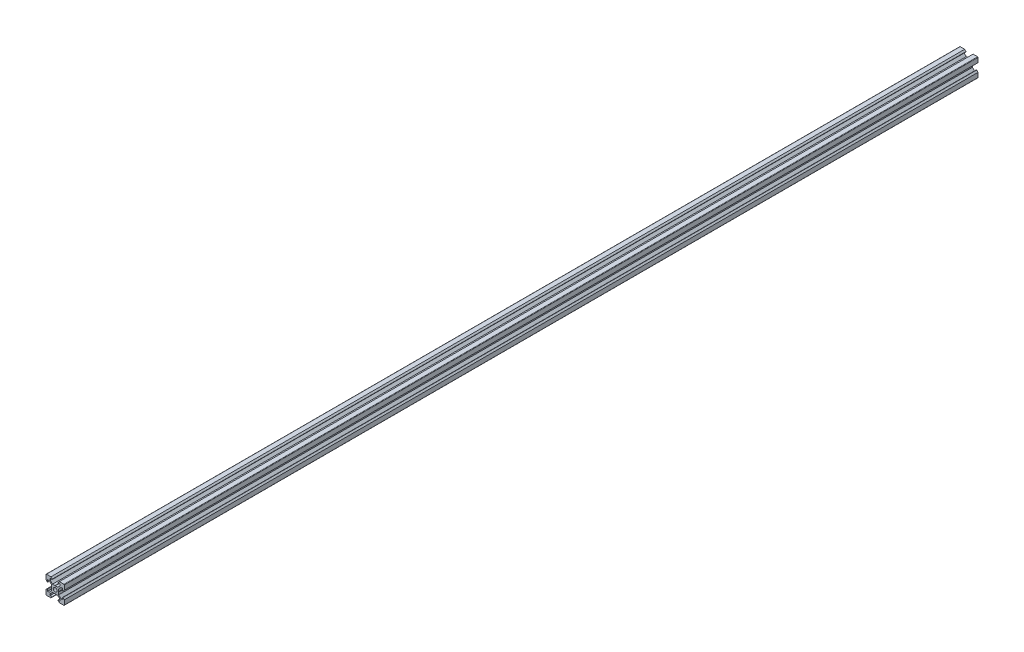
from build123d import *

# Parameters (mm, degrees)
SKETCH1_R           = 2.1
BOSS_EXTRUDE1_DEPTH = 500


with BuildPart() as part:
    # Sketch1 → Boss-Extrude1 (new body, symmetric)
    with BuildSketch(Plane.XY):
        with BuildLine():
            Line((4.58, -10), (9.5, -10))
            ThreePointArc((9.5, -10), (9.853553391, -9.853553391), (10, -9.5))
            Line((10, -9.5), (10, -4.58))
            Line((10, -4.58), (8.545, -3.125))
            Line((8.545, -3.125), (8.2, -3.125))
            Line((8.2, -3.125), (8.2, -5.5))
            Line((8.2, -5.5), (6.560660172, -5.5))
            Line((6.560660172, -5.5), (3.9, -2.839339828))
            Line((3.9, -2.839339828), (3.9, -0.21))
            Line((3.9, -0.21), (3.69, 0))
            Line((3.69, 0), (3.9, 0.21))
            Line((3.9, 0.21), (3.9, 2.839339828))
            Line((3.9, 2.839339828), (6.560660172, 5.5))
            Line((6.560660172, 5.5), (8.2, 5.5))
            Line((8.2, 5.5), (8.2, 3.125))
            Line((8.2, 3.125), (8.545, 3.125))
            Line((8.545, 3.125), (10, 4.58))
            Line((10, 4.58), (10, 9.5))
            ThreePointArc((10, 9.5), (9.853553391, 9.853553391), (9.5, 10))
            Line((9.5, 10), (4.58, 10))
            Line((4.58, 10), (3.125, 8.545))
            Line((3.125, 8.545), (3.125, 8.2))
            Line((3.125, 8.2), (5.5, 8.2))
            Line((5.5, 8.2), (5.5, 6.560660172))
            Line((5.5, 6.560660172), (2.839339828, 3.9))
            Line((2.839339828, 3.9), (0.21, 3.9))
            Line((0.21, 3.9), (0, 3.69))
            Line((0, 3.69), (-0.21, 3.9))
            Line((-0.21, 3.9), (-2.839339828, 3.9))
            Line((-2.839339828, 3.9), (-5.5, 6.560660172))
            Line((-5.5, 6.560660172), (-5.5, 8.2))
            Line((-5.5, 8.2), (-3.125, 8.2))
            Line((-3.125, 8.2), (-3.125, 8.545))
            Line((-3.125, 8.545), (-4.58, 10))
            Line((-4.58, 10), (-9.5, 10))
            ThreePointArc((-9.5, 10), (-9.853553391, 9.853553391), (-10, 9.5))
            Line((-10, 9.5), (-10, 4.58))
            Line((-10, 4.58), (-8.545, 3.125))
            Line((-8.545, 3.125), (-8.2, 3.125))
            Line((-8.2, 3.125), (-8.2, 5.5))
            Line((-8.2, 5.5), (-6.560660172, 5.5))
            Line((-6.560660172, 5.5), (-3.9, 2.839339828))
            Line((-3.9, 2.839339828), (-3.9, 0.21))
            Line((-3.9, 0.21), (-3.69, 0))
            Line((-3.69, 0), (-3.9, -0.21))
            Line((-3.9, -0.21), (-3.9, -2.839339828))
            Line((-3.9, -2.839339828), (-6.560660172, -5.5))
            Line((-6.560660172, -5.5), (-8.2, -5.5))
            Line((-8.2, -5.5), (-8.2, -3.125))
            Line((-8.2, -3.125), (-8.545, -3.125))
            Line((-8.545, -3.125), (-10, -4.58))
            Line((-10, -4.58), (-10, -9.5))
            ThreePointArc((-10, -9.5), (-9.853553391, -9.853553391), (-9.5, -10))
            Line((-9.5, -10), (-4.58, -10))
            Line((-4.58, -10), (-3.125, -8.545))
            Line((-3.125, -8.545), (-3.125, -8.2))
            Line((-3.125, -8.2), (-5.5, -8.2))
            Line((-5.5, -8.2), (-5.5, -6.560660172))
            Line((-5.5, -6.560660172), (-2.839339828, -3.9))
            Line((-2.839339828, -3.9), (-0.21, -3.9))
            Line((-0.21, -3.9), (0, -3.69))
            Line((0, -3.69), (0.21, -3.9))
            Line((0.21, -3.9), (2.839339828, -3.9))
            Line((2.839339828, -3.9), (5.5, -6.560660172))
            Line((5.5, -6.560660172), (5.5, -8.2))
            Line((5.5, -8.2), (3.125, -8.2))
            Line((3.125, -8.2), (3.125, -8.545))
            Line((3.125, -8.545), (4.58, -10))
        make_face()
        Circle(SKETCH1_R, mode=Mode.SUBTRACT)
    extrude(amount=BOSS_EXTRUDE1_DEPTH, both=True)


solid = part.part
